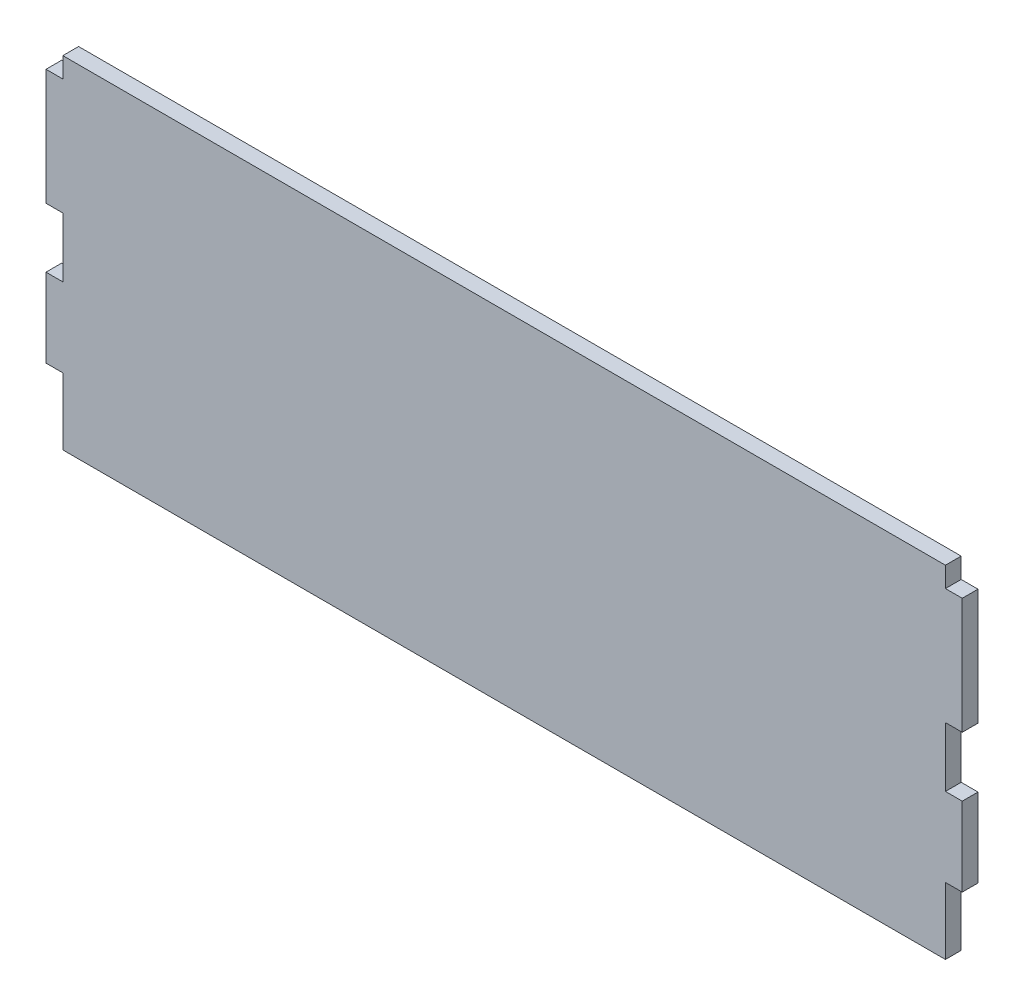
from build123d import *

# Parameters (mm, degrees)
SALIENTE_EXTRUIR1_DEPTH = 3
CROQUIS2_W              = 199.8453191
CROQUIS2_H              = 35.001157583
CORTAR_EXTRUIR1_DEPTH   = 4


with BuildPart() as part:
    # Croquis1 → Saliente-Extruir1 (new body)
    with BuildSketch(Plane.XY):
        Polygon((-84, 37.295390898), (-87.2, 37.295390898), (-87.2, 22.295390898), (-84, 22.295390898), (-84, 11.147890898), (-87.2, 11.147890898), (-87.2, -10.945390898), (-84, -10.945390898), (-84, -22.295390898), (-87.2, -22.295390898), (-87.2, -37.295390898), (-84, -37.295390898), (-84, -50), (84, -50), (84, -37.295390898), (87.2, -37.295390898), (87.2, -22.295390898), (84, -22.295390898), (84, -10.945390898), (87.2, -10.945390898), (87.2, 11.147890898), (84, 11.147890898), (84, 22.295390898), (87.2, 22.295390898), (87.2, 37.295390898), (84, 37.295390898), (84, 50), (-84, 50), align=None)
    extrude(amount=SALIENTE_EXTRUIR1_DEPTH)

    # Croquis2 → Cortar-Extruir1 (cut, through all)
    with BuildSketch(Plane.XY.offset(3)):
        with Locations((9.220735062, 32.499421209)):
            Rectangle(CROQUIS2_W, CROQUIS2_H)
    extrude(amount=-CORTAR_EXTRUIR1_DEPTH, mode=Mode.SUBTRACT)


solid = part.part
